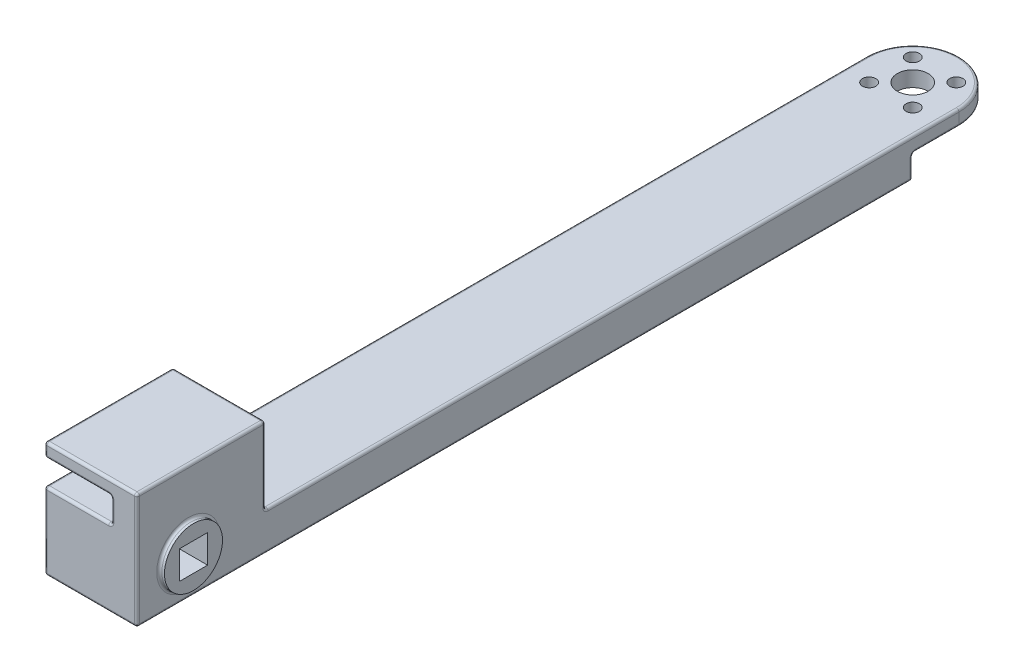
from build123d import *

# Parameters (mm, degrees)
SKETCH1_W                = 18
SKETCH1_H                = 15
BOSS_EXTRUDE1_DEPTH      = 40
BOSS_EXTRUDE1_DEPTH_BACK = 150
SKETCH2_R                = 5.65
BOSS_EXTRUDE2_DEPTH      = 1
CUT_EXTRUDE1_REACH       = 22
SKETCH3_W                = 5.5
SKETCH3_H                = 5.5
CUT_EXTRUDE2_REACH       = 21
SKETCH4_W                = 135
SKETCH4_H                = 7.5
SKETCH4_W_2              = 30
SKETCH4_H_2              = 15
SKETCH6_R                = 9
BOSS_EXTRUDE4_DEPTH      = 3
SKETCH9_R                = 3
SKETCH9_R_2              = 1.3
CUT_EXTRUDE3_DEPTH       = 3
CUT_EXTRUDE5_REACH       = 21
SKETCH16_W               = 9
SKETCH16_H               = 4.5
BOSS_EXTRUDE7_DEPTH      = 25
FILLET2_R                = 0.5


with BuildPart() as part:
    # Sketch1 → Boss-Extrude1 (new body, two sides)
    with BuildSketch(Plane.XY) as boss_extrude1_sk:
        with Locations((9, 7.5)):
            Rectangle(SKETCH1_W, SKETCH1_H)
    extrude(amount=BOSS_EXTRUDE1_DEPTH)
    extrude(boss_extrude1_sk.sketch, amount=-BOSS_EXTRUDE1_DEPTH_BACK)

    # Sketch2 → Boss-Extrude2 (add)
    with BuildSketch(Plane(origin=(18, 0, 0), x_dir=(0, 0, -1), z_dir=(1, 0, 0))):
        with Locations((0, 7.5)):
            Circle(SKETCH2_R)
    boss_extrude2 = extrude(amount=BOSS_EXTRUDE2_DEPTH)

    # Mirror1: Boss-Extrude2 across plane
    add(boss_extrude2.mirror(Plane(origin=(9, 0, 0), x_dir=(0, 0, 1), z_dir=(1, 0, 0))))

    # Sketch3 → Cut-Extrude1 (cut, up to next)
    with BuildSketch(Plane(origin=(19, 0, 0), x_dir=(0, 0, -1), z_dir=(1, 0, 0)), mode=Mode.PRIVATE) as cut_extrude1_sk1:
        with Locations((0, 7.5)):
            Rectangle(SKETCH3_W, SKETCH3_H)
    cut_extrude1_tool1 = extrude(cut_extrude1_sk1.sketch, amount=-CUT_EXTRUDE1_REACH, mode=Mode.PRIVATE) & part.part
    add(cut_extrude1_tool1.solids().sort_by_distance((19, 7.5, 0))[0], mode=Mode.SUBTRACT)

    # Sketch4 → Cut-Extrude2 (cut, up to next)
    with BuildSketch(Plane(origin=(18, 0, 0), x_dir=(0, 0, -1), z_dir=(1, 0, 0)), mode=Mode.PRIVATE) as cut_extrude2_sk1:
        with Locations((82.5, 11.25)):
            Rectangle(SKETCH4_W, SKETCH4_H)
    cut_extrude2_tool1 = extrude(cut_extrude2_sk1.sketch, amount=-CUT_EXTRUDE2_REACH, mode=Mode.PRIVATE) & part.part
    add(cut_extrude2_tool1.solids().sort_by_distance((18, 11.25, -82.5))[0], mode=Mode.SUBTRACT)
    # Sketch4 → Cut-Extrude2 (cut, up to next)
    with BuildSketch(Plane(origin=(18, 0, 0), x_dir=(0, 0, -1), z_dir=(1, 0, 0)), mode=Mode.PRIVATE) as cut_extrude2_sk2:
        with Locations((-25, 7.5)):
            Rectangle(SKETCH4_W_2, SKETCH4_H_2)
    cut_extrude2_tool2 = extrude(cut_extrude2_sk2.sketch, amount=-CUT_EXTRUDE2_REACH, mode=Mode.PRIVATE) & part.part
    add(cut_extrude2_tool2.solids().sort_by_distance((18, 7.5, 25))[0], mode=Mode.SUBTRACT)

    # Sketch6 → Boss-Extrude4 (add)
    with BuildSketch(Plane(origin=(0, 7.5, 0), x_dir=(1, 0, 0), z_dir=(0, 1, 0))):
        with Locations((9, 150)):
            Circle(SKETCH6_R)
    extrude(amount=-BOSS_EXTRUDE4_DEPTH)

    # Sketch9 → Cut-Extrude3 (cut)
    with BuildSketch(Plane(origin=(0, 4.5, 0), x_dir=(-1, 0, 0), z_dir=(0, -1, 0))):
        with Locations((-9, 150)):
            Circle(SKETCH9_R)
        with Locations((-4.757359313, 154.242640687)):
            Circle(SKETCH9_R_2)
        with Locations((-4.757359313, 145.757359313)):
            Circle(SKETCH9_R_2)
        with Locations((-13.242640687, 145.757359313)):
            Circle(SKETCH9_R_2)
        with Locations((-13.242640687, 154.242640687)):
            Circle(SKETCH9_R_2)
    extrude(amount=-CUT_EXTRUDE3_DEPTH, mode=Mode.SUBTRACT)

    # Sketch16 → Cut-Extrude5 (cut, up to next)
    with BuildSketch(Plane(origin=(18, 0, 0), x_dir=(0, 0, -1), z_dir=(1, 0, 0)), mode=Mode.PRIVATE) as cut_extrude5_sk1:
        with Locations((145.5, 2.25)):
            Rectangle(SKETCH16_W, SKETCH16_H)
    cut_extrude5_tool1 = extrude(cut_extrude5_sk1.sketch, amount=-CUT_EXTRUDE5_REACH, mode=Mode.PRIVATE) & part.part
    add(cut_extrude5_tool1.solids().sort_by_distance((18, 2.25, -145.5))[0], mode=Mode.SUBTRACT)

    # Sketch15 → Boss-Extrude7 (add)
    with BuildSketch(Plane.XY.offset(10)):
        Polygon((18, 15), (13, 15), (13, 19.8), (0, 19.8), (0, 22.5), (18, 22.5), align=None)
    extrude(amount=-BOSS_EXTRUDE7_DEPTH)

    # Fillet2
    fillet2_edges = [part.edges().sort_by_distance(p)[0] for p in [
        (0, 0, -65.5),
        (18, 0, -65.5),
        (0, 4.5, -145.5),
        (9, 4.5, -141),
        (0, 2.25, -141),
        (9, 0, -141),
        (18, 4.5, -145.5),
        (18, 2.25, -141),
        (18, 22.5, -2.5),
        (13, 17.4, -15),
        (13, 15, -2.5),
        (6.5, 19.8, -15),
        (13, 19.8, -2.5),
        (0, 21.15, -15),
        (0, 19.8, -2.5),
        (9, 22.5, -15),
        (0, 22.5, -2.5),
        (9, 22.5, 10),
        (0, 21.15, 10),
        (6.5, 19.8, 10),
        (13, 17.4, 10),
        (18, 7.5, 5.65),
        (0, 7.5, 5.65),
        (0, 15, -2.5),
        (0, 7.5, -82.5),
        (0, 11.25, -15),
        (9, 7.5, -15),
        (6.5, 15, -15),
        (18, 15, -15),
        (18, 7.5, -82.5),
        (0, 7.5, 10),
        (6.5, 15, 10),
        (9, 0, 10),
        (18, 11.25, 10),
        (9, 4.5, -159),
        (9, 7.5, -159),
    ]]
    fillet(fillet2_edges, radius=FILLET2_R)


solid = part.part
